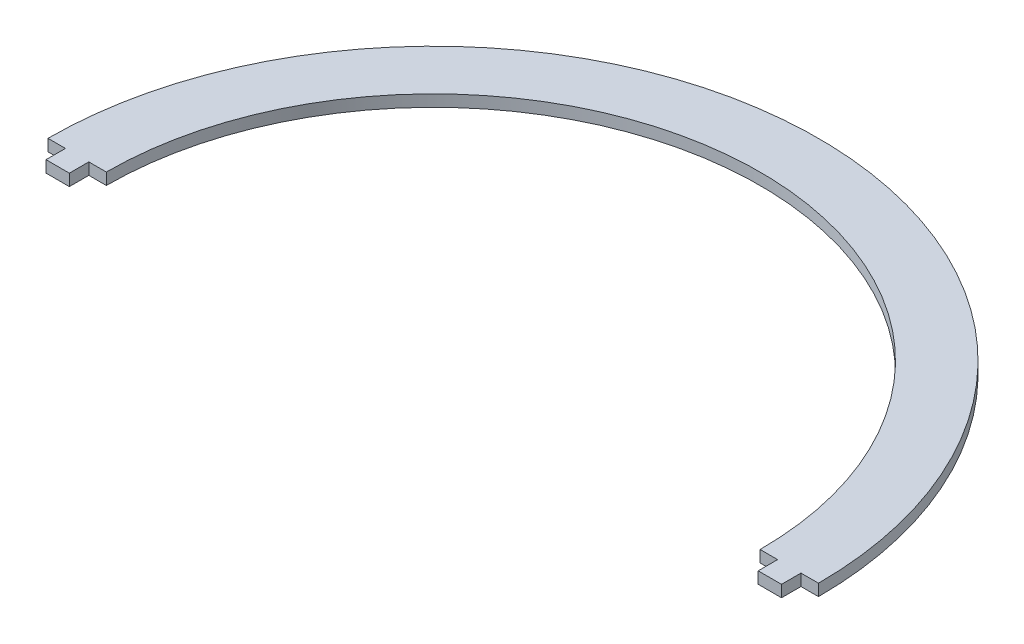
from build123d import *

# Parameters (mm, degrees)
BOSS_EXTRUDE1_DEPTH = 1.5


with BuildPart() as part:
    # Sketch1 → Boss-Extrude1 (new body, symmetric)
    with BuildSketch(Plane(origin=(0, 0, 0), x_dir=(1, 0, 0), z_dir=(0, 1, 0))):
        with BuildLine():
            Line((-94.5, 0), (-88.5, 0))
            Line((-88.5, 0), (-88.5, 5))
            Line((-88.5, 5), (-84, 5))
            ThreePointArc((-84, 5), (0, 89), (84, 5))
            Line((84, 5), (88.5, 5))
            Line((88.5, 5), (88.5, 0))
            Line((88.5, 0), (94.5, 0))
            Line((94.5, 0), (94.5, 5))
            Line((94.5, 5), (99, 5))
            ThreePointArc((99, 5), (0, 104), (-99, 5))
            Line((-99, 5), (-94.5, 5))
            Line((-94.5, 5), (-94.5, 0))
        make_face()
    extrude(amount=BOSS_EXTRUDE1_DEPTH, both=True)


solid = part.part
